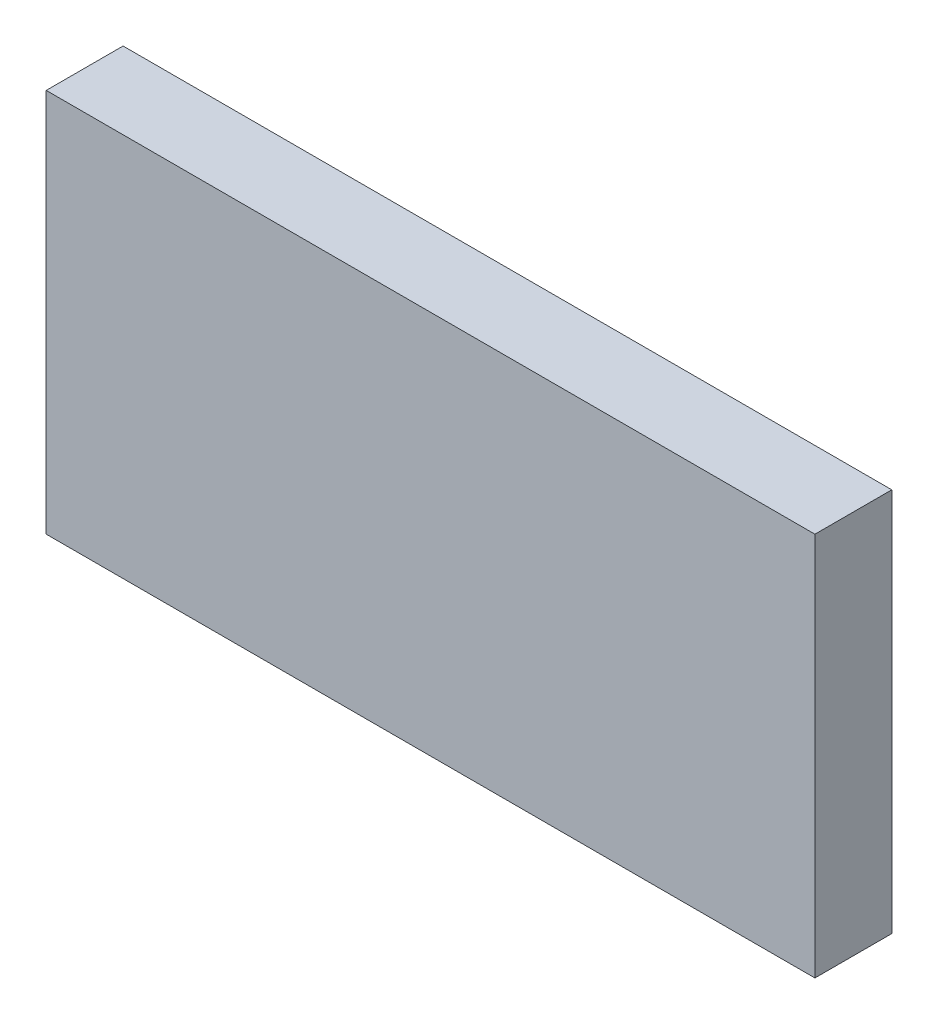
from build123d import *

# Parameters (mm, degrees)
SKIZZE1_W                       = 100
SKIZZE1_H                       = 50
AUFSATZ_LINEAR_AUSTRAGEN1_DEPTH = 10


with BuildPart() as part:
    # Skizze1 → Aufsatz-Linear austragen1 (new body)
    with BuildSketch(Plane.XY):
        with Locations((50, -25)):
            Rectangle(SKIZZE1_W, SKIZZE1_H)
    extrude(amount=AUFSATZ_LINEAR_AUSTRAGEN1_DEPTH)


solid = part.part
